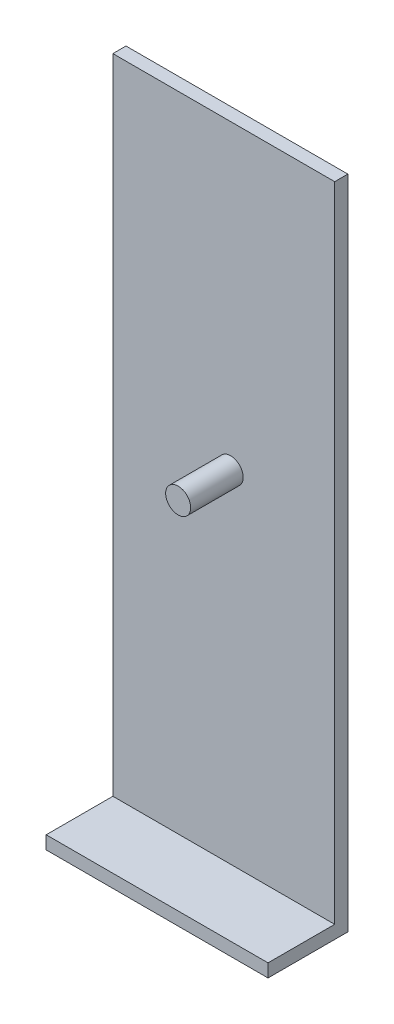
from build123d import *

# Parameters (mm, degrees)
SKETCH1_W           = 84.5
SKETCH1_H           = 250
BOSS_EXTRUDE1_DEPTH = 5
SKETCH2_W           = 84.5
SKETCH2_H           = 5
BOSS_EXTRUDE2_DEPTH = 25.4
SKETCH3_R           = 4.7625
BOSS_EXTRUDE3_DEPTH = 20


with BuildPart() as part:
    # Sketch1 → Boss-Extrude1 (new body)
    with BuildSketch(Plane.XY):
        Rectangle(SKETCH1_W, SKETCH1_H)
    extrude(amount=BOSS_EXTRUDE1_DEPTH)

    # Sketch2 → Boss-Extrude2 (add)
    with BuildSketch(Plane.XY.offset(5)):
        with Locations((0, -122.5)):
            Rectangle(SKETCH2_W, SKETCH2_H)
    extrude(amount=BOSS_EXTRUDE2_DEPTH)

    # Sketch3 → Boss-Extrude3 (add)
    with BuildSketch(Plane.XY.offset(5)):
        with Locations((2.625, 10)):
            Circle(SKETCH3_R)
    extrude(amount=BOSS_EXTRUDE3_DEPTH)


solid = part.part
